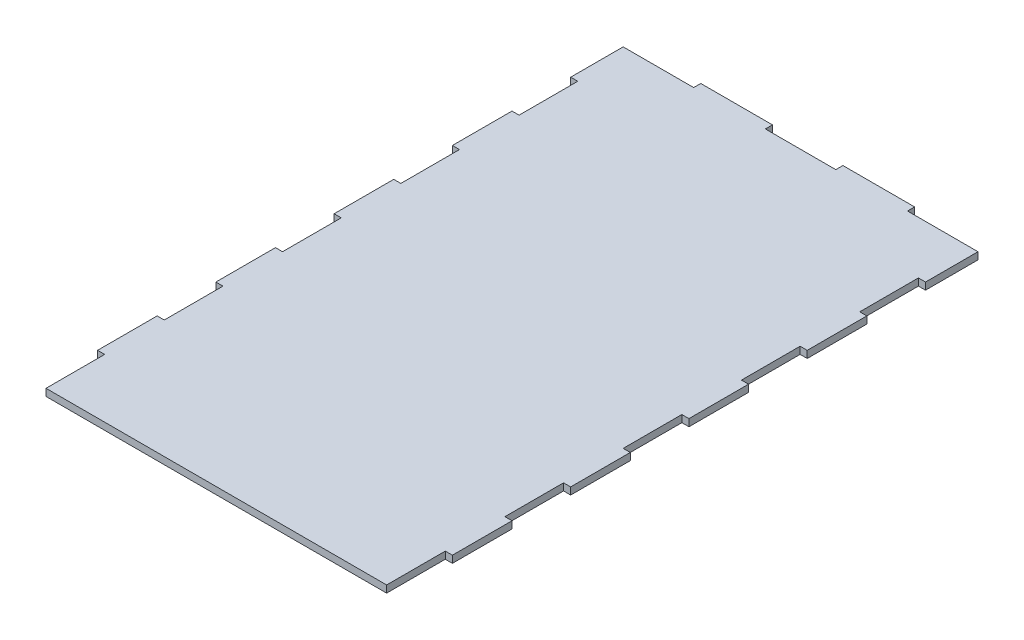
from build123d import *

# Parameters (mm, degrees)
BOSS_EXTRUDE1_DEPTH = 3


with BuildPart() as part:
    # Sketch1 → Boss-Extrude1 (new body)
    with BuildSketch(Plane(origin=(0, 0, 0), x_dir=(1, 0, 0), z_dir=(0, 1, 0))):
        Polygon((3, 24.8), (3, 0), (147, 0), (147, 24.8), (150, 24.8), (150, 50), (147, 50), (147, 74.8), (150, 74.8), (150, 100), (147, 100), (147, 124.8), (150, 124.8), (150, 150), (147, 150), (147, 174.8), (150, 174.8), (150, 200), (147, 200), (147, 224.8), (150, 224.8), (150, 247), (120.2, 247), (120.2, 250), (89.9, 250), (89.9, 247), (60.1, 247), (60.1, 250), (29.8, 250), (29.8, 247), (0, 247), (0, 224.8), (3, 224.8), (3, 200), (0, 200), (0, 174.8), (3, 174.8), (3, 150), (0, 150), (0, 124.8), (3, 124.8), (3, 100), (0, 100), (0, 74.8), (3, 74.8), (3, 50), (0, 50), (0, 24.8), align=None)
    extrude(amount=BOSS_EXTRUDE1_DEPTH)


solid = part.part
